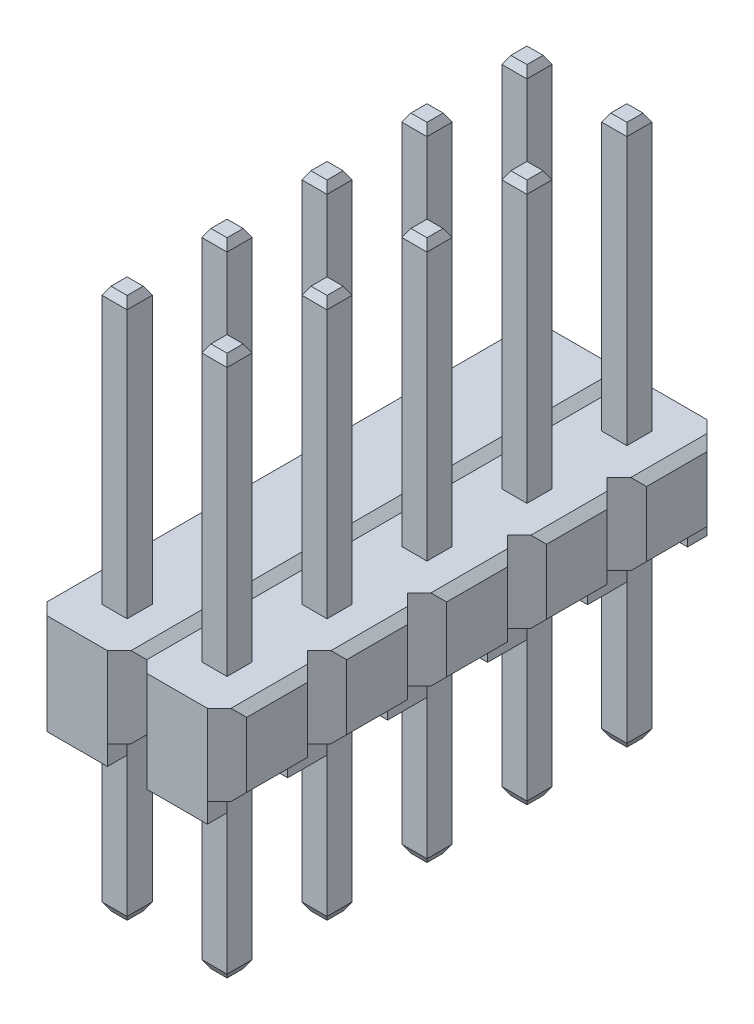
from build123d import *

# Parameters (mm, degrees)
SKETCH1_W                = 0.64
SKETCH1_H                = 0.64
BOSS_EXTRUDE1_DEPTH      = 2.05
CUT_EXTRUDE1_DEPTH       = 10
SKETCH3_W                = 1.54
SKETCH3_H                = 0.5
SKETCH3_H_2              = 1
BOSS_EXTRUDE2_DEPTH      = 0.5
SKETCH4_W                = 0.64
SKETCH4_H                = 0.64
BOSS_EXTRUDE3_DEPTH      = 7
BOSS_EXTRUDE3_DEPTH_BACK = 6.75
CHAMFER1_SIZE            = 0.2
CHAMFER1_SIZE2           = 0.115470054
CHAMFER1_PART_2_SIZE     = 0.2
CHAMFER1_PART_2_SIZE2    = 0.115470054
CHAMFER1_PART_3_SIZE     = 0.2
CHAMFER1_PART_3_SIZE2    = 0.115470054
CHAMFER1_PART_4_SIZE     = 0.2
CHAMFER1_PART_4_SIZE2    = 0.115470054
CHAMFER1_PART_5_SIZE     = 0.2
CHAMFER1_PART_5_SIZE2    = 0.115470054
CHAMFER1_PART_6_SIZE     = 0.2
CHAMFER1_PART_6_SIZE2    = 0.115470054
CHAMFER1_PART_7_SIZE     = 0.2
CHAMFER1_PART_7_SIZE2    = 0.115470054
CHAMFER1_PART_8_SIZE     = 0.2
CHAMFER1_PART_8_SIZE2    = 0.115470054
CHAMFER1_PART_9_SIZE     = 0.2
CHAMFER1_PART_9_SIZE2    = 0.115470054
CHAMFER1_PART_10_SIZE    = 0.2
CHAMFER1_PART_10_SIZE2   = 0.115470054
CHAMFER1_PART_11_SIZE    = 0.2
CHAMFER1_PART_11_SIZE2   = 0.115470054
CHAMFER1_PART_12_SIZE    = 0.2
CHAMFER1_PART_12_SIZE2   = 0.115470054
CHAMFER1_PART_13_SIZE    = 0.2
CHAMFER1_PART_13_SIZE2   = 0.115470054
CHAMFER1_PART_14_SIZE    = 0.2
CHAMFER1_PART_14_SIZE2   = 0.115470054
CHAMFER1_PART_15_SIZE    = 0.2
CHAMFER1_PART_15_SIZE2   = 0.115470054
CHAMFER1_PART_16_SIZE    = 0.2
CHAMFER1_PART_16_SIZE2   = 0.115470054
CHAMFER1_PART_17_SIZE    = 0.2
CHAMFER1_PART_17_SIZE2   = 0.115470054
CHAMFER1_PART_18_SIZE    = 0.2
CHAMFER1_PART_18_SIZE2   = 0.115470054
CHAMFER1_PART_19_SIZE    = 0.2
CHAMFER1_PART_19_SIZE2   = 0.115470054
CHAMFER1_PART_20_SIZE    = 0.2
CHAMFER1_PART_20_SIZE2   = 0.115470054
CHAMFER1_PART_21_SIZE    = 0.2
CHAMFER1_PART_21_SIZE2   = 0.115470054
CHAMFER1_PART_22_SIZE    = 0.2
CHAMFER1_PART_22_SIZE2   = 0.115470054
CHAMFER1_PART_23_SIZE    = 0.2
CHAMFER1_PART_23_SIZE2   = 0.115470054
CHAMFER1_PART_24_SIZE    = 0.2
CHAMFER1_PART_24_SIZE2   = 0.115470054
CHAMFER1_PART_25_SIZE    = 0.2
CHAMFER1_PART_25_SIZE2   = 0.115470054
CHAMFER1_PART_26_SIZE    = 0.2
CHAMFER1_PART_26_SIZE2   = 0.115470054
CHAMFER1_PART_27_SIZE    = 0.2
CHAMFER1_PART_27_SIZE2   = 0.115470054
CHAMFER1_PART_28_SIZE    = 0.2
CHAMFER1_PART_28_SIZE2   = 0.115470054
CHAMFER1_PART_29_SIZE    = 0.2
CHAMFER1_PART_29_SIZE2   = 0.115470054
CHAMFER1_PART_30_SIZE    = 0.2
CHAMFER1_PART_30_SIZE2   = 0.115470054
CHAMFER1_PART_31_SIZE    = 0.2
CHAMFER1_PART_31_SIZE2   = 0.115470054
CHAMFER1_PART_32_SIZE    = 0.2
CHAMFER1_PART_32_SIZE2   = 0.115470054
CHAMFER1_PART_33_SIZE    = 0.2
CHAMFER1_PART_33_SIZE2   = 0.115470054
CHAMFER1_PART_34_SIZE    = 0.2
CHAMFER1_PART_34_SIZE2   = 0.115470054
CHAMFER1_PART_35_SIZE    = 0.2
CHAMFER1_PART_35_SIZE2   = 0.115470054
CHAMFER1_PART_36_SIZE    = 0.2
CHAMFER1_PART_36_SIZE2   = 0.115470054
CHAMFER1_PART_37_SIZE    = 0.2
CHAMFER1_PART_37_SIZE2   = 0.115470054
CHAMFER1_PART_38_SIZE    = 0.2
CHAMFER1_PART_38_SIZE2   = 0.115470054
CHAMFER1_PART_39_SIZE    = 0.2
CHAMFER1_PART_39_SIZE2   = 0.115470054
CHAMFER1_PART_40_SIZE    = 0.2
CHAMFER1_PART_40_SIZE2   = 0.115470054
CHAMFER1_PART_41_SIZE    = 0.2
CHAMFER1_PART_41_SIZE2   = 0.115470054
CHAMFER1_PART_42_SIZE    = 0.2
CHAMFER1_PART_42_SIZE2   = 0.115470054
CHAMFER1_PART_43_SIZE    = 0.2
CHAMFER1_PART_43_SIZE2   = 0.115470054
CHAMFER1_PART_44_SIZE    = 0.2
CHAMFER1_PART_44_SIZE2   = 0.115470054
CHAMFER1_PART_45_SIZE    = 0.2
CHAMFER1_PART_45_SIZE2   = 0.115470054
CHAMFER1_PART_46_SIZE    = 0.2
CHAMFER1_PART_46_SIZE2   = 0.115470054
CHAMFER1_PART_47_SIZE    = 0.2
CHAMFER1_PART_47_SIZE2   = 0.115470054
CHAMFER1_PART_48_SIZE    = 0.2
CHAMFER1_PART_48_SIZE2   = 0.115470054
CHAMFER1_PART_49_SIZE    = 0.2
CHAMFER1_PART_49_SIZE2   = 0.115470054
CHAMFER1_PART_50_SIZE    = 0.2
CHAMFER1_PART_50_SIZE2   = 0.115470054
CHAMFER1_PART_51_SIZE    = 0.2
CHAMFER1_PART_51_SIZE2   = 0.115470054
CHAMFER1_PART_52_SIZE    = 0.2
CHAMFER1_PART_52_SIZE2   = 0.115470054
CHAMFER1_PART_53_SIZE    = 0.2
CHAMFER1_PART_53_SIZE2   = 0.115470054
CHAMFER1_PART_54_SIZE    = 0.2
CHAMFER1_PART_54_SIZE2   = 0.115470054
CHAMFER1_PART_55_SIZE    = 0.2
CHAMFER1_PART_55_SIZE2   = 0.115470054
CHAMFER1_PART_56_SIZE    = 0.2
CHAMFER1_PART_56_SIZE2   = 0.115470054
CHAMFER1_PART_57_SIZE    = 0.2
CHAMFER1_PART_57_SIZE2   = 0.115470054
CHAMFER1_PART_58_SIZE    = 0.2
CHAMFER1_PART_58_SIZE2   = 0.115470054
CHAMFER1_PART_59_SIZE    = 0.2
CHAMFER1_PART_59_SIZE2   = 0.115470054
CHAMFER1_PART_60_SIZE    = 0.2
CHAMFER1_PART_60_SIZE2   = 0.115470054
CHAMFER1_PART_61_SIZE    = 0.2
CHAMFER1_PART_61_SIZE2   = 0.115470054
CHAMFER1_PART_62_SIZE    = 0.2
CHAMFER1_PART_62_SIZE2   = 0.115470054
CHAMFER1_PART_63_SIZE    = 0.2
CHAMFER1_PART_63_SIZE2   = 0.115470054
CHAMFER1_PART_64_SIZE    = 0.2
CHAMFER1_PART_64_SIZE2   = 0.115470054
CHAMFER1_PART_65_SIZE    = 0.2
CHAMFER1_PART_65_SIZE2   = 0.115470054
CHAMFER1_PART_66_SIZE    = 0.2
CHAMFER1_PART_66_SIZE2   = 0.115470054
CHAMFER1_PART_67_SIZE    = 0.2
CHAMFER1_PART_67_SIZE2   = 0.115470054
CHAMFER1_PART_68_SIZE    = 0.2
CHAMFER1_PART_68_SIZE2   = 0.115470054
CHAMFER1_PART_69_SIZE    = 0.2
CHAMFER1_PART_69_SIZE2   = 0.115470054
CHAMFER1_PART_70_SIZE    = 0.2
CHAMFER1_PART_70_SIZE2   = 0.115470054
CHAMFER1_PART_71_SIZE    = 0.2
CHAMFER1_PART_71_SIZE2   = 0.115470054
CHAMFER1_PART_72_SIZE    = 0.2
CHAMFER1_PART_72_SIZE2   = 0.115470054
CHAMFER1_PART_73_SIZE    = 0.2
CHAMFER1_PART_73_SIZE2   = 0.115470054
CHAMFER1_PART_74_SIZE    = 0.2
CHAMFER1_PART_74_SIZE2   = 0.115470054
CHAMFER1_PART_75_SIZE    = 0.2
CHAMFER1_PART_75_SIZE2   = 0.115470054
CHAMFER1_PART_76_SIZE    = 0.2
CHAMFER1_PART_76_SIZE2   = 0.115470054
CHAMFER1_PART_77_SIZE    = 0.2
CHAMFER1_PART_77_SIZE2   = 0.115470054
CHAMFER1_PART_78_SIZE    = 0.2
CHAMFER1_PART_78_SIZE2   = 0.115470054
CHAMFER1_PART_79_SIZE    = 0.2
CHAMFER1_PART_79_SIZE2   = 0.115470054
CHAMFER1_PART_80_SIZE    = 0.2
CHAMFER1_PART_80_SIZE2   = 0.115470054
SKETCH5_R                = 0.125
CUT_EXTRUDE2_DEPTH       = 1
SCALE1_SCALE             = 0.5


with BuildPart() as part:
    # Sketch1 → Boss-Extrude1 (new body)
    with BuildSketch(Plane(origin=(0, 0, 0), x_dir=(1, 0, 0), z_dir=(0, 1, 0))):
        Polygon((2.04, 1.27), (2.54, 0.77), (2.54, -0.77), (2.04, -1.27), (2.54, -1.77), (2.54, -3.31), (2.04, -3.81), (2.54, -4.31), (2.54, -5.85), (2.04, -6.35), (0.5, -6.35), (0, -5.85), (-0.5, -6.35), (-2.04, -6.35), (-2.54, -5.85), (-2.54, -4.31), (-2.04, -3.81), (-2.54, -3.31), (-2.54, -1.77), (-2.04, -1.27), (-2.54, -0.77), (-2.54, 0.77), (-2.04, 1.27), (-2.54, 1.77), (-2.54, 3.31), (-2.04, 3.81), (-2.54, 4.31), (-2.54, 5.85), (-2.04, 6.35), (-0.5, 6.35), (0, 5.85), (0.5, 6.35), (2.04, 6.35), (2.54, 5.85), (2.54, 4.31), (2.04, 3.81), (2.54, 3.31), (2.54, 1.77), align=None)
        Polygon((0, 0.77), (0.5, 1.27), (0, 1.77), (-0.5, 1.27), align=None, mode=Mode.SUBTRACT)
        Polygon((0, 4.31), (-0.5, 3.81), (0, 3.31), (0.5, 3.81), align=None, mode=Mode.SUBTRACT)
        Polygon((0.5, -1.27), (0, -0.77), (-0.5, -1.27), (0, -1.77), align=None, mode=Mode.SUBTRACT)
        with Locations((-1.27, 0)):
            Rectangle(SKETCH1_W, SKETCH1_H, mode=Mode.SUBTRACT)
        with Locations((1.27, 0)):
            Rectangle(SKETCH1_W, SKETCH1_H, mode=Mode.SUBTRACT)
        with Locations((1.27, 5.08)):
            Rectangle(SKETCH1_W, SKETCH1_H, mode=Mode.SUBTRACT)
        with Locations((1.27, 2.54)):
            Rectangle(SKETCH1_W, SKETCH1_H, mode=Mode.SUBTRACT)
        with Locations((-1.27, 2.54)):
            Rectangle(SKETCH1_W, SKETCH1_H, mode=Mode.SUBTRACT)
        Polygon((0, -4.31), (0.5, -3.81), (0, -3.31), (-0.5, -3.81), align=None, mode=Mode.SUBTRACT)
        with Locations((-1.27, 5.08)):
            Rectangle(SKETCH1_W, SKETCH1_H, mode=Mode.SUBTRACT)
        with Locations((-1.27, -5.08)):
            Rectangle(SKETCH1_W, SKETCH1_H, mode=Mode.SUBTRACT)
        with Locations((1.27, -5.08)):
            Rectangle(SKETCH1_W, SKETCH1_H, mode=Mode.SUBTRACT)
        with Locations((1.27, -2.54)):
            Rectangle(SKETCH1_W, SKETCH1_H, mode=Mode.SUBTRACT)
        with Locations((-1.27, -2.54)):
            Rectangle(SKETCH1_W, SKETCH1_H, mode=Mode.SUBTRACT)
    extrude(amount=-BOSS_EXTRUDE1_DEPTH)

    # Sketch2 → Cut-Extrude1 (cut, symmetric)
    with BuildSketch(Plane.XY):
        Polygon((-2.54, -0.2), (-2.34, 0), (-2.54, 0), align=None)
        Polygon((-0.2, 0), (0.2, 0), (0, -0.2), align=None)
        Polygon((2.54, 0), (2.34, 0), (2.54, -0.2), align=None)
        Polygon((2.54, -1.85), (2.54, -2.05), (2.34, -2.05), align=None)
        Polygon((0, -1.85), (-0.2, -2.05), (0.2, -2.05), align=None)
        Polygon((-2.54, -2.05), (-2.54, -1.85), (-2.34, -2.05), align=None)
    extrude(amount=CUT_EXTRUDE1_DEPTH, both=True, mode=Mode.SUBTRACT)

    # Sketch3 → Boss-Extrude2 (add)
    with BuildSketch(Plane.XZ.offset(2.05)):
        with Locations((-1.27, 6.1)):
            Rectangle(SKETCH3_W, SKETCH3_H)
        with Locations((1.27, 6.1)):
            Rectangle(SKETCH3_W, SKETCH3_H)
        with Locations((-1.27, -1.27)):
            Rectangle(SKETCH3_W, SKETCH3_H_2)
        with Locations((1.27, -1.27)):
            Rectangle(SKETCH3_W, SKETCH3_H_2)
        with Locations((-1.27, -3.81)):
            Rectangle(SKETCH3_W, SKETCH3_H_2)
        with Locations((1.27, -3.81)):
            Rectangle(SKETCH3_W, SKETCH3_H_2)
        with Locations((-1.27, -6.1)):
            Rectangle(SKETCH3_W, SKETCH3_H)
        with Locations((1.27, -6.1)):
            Rectangle(SKETCH3_W, SKETCH3_H)
        with Locations((-1.27, 3.81)):
            Rectangle(SKETCH3_W, SKETCH3_H_2)
        with Locations((-1.27, 1.27)):
            Rectangle(SKETCH3_W, SKETCH3_H_2)
        with Locations((1.27, 3.81)):
            Rectangle(SKETCH3_W, SKETCH3_H_2)
        with Locations((1.27, 1.27)):
            Rectangle(SKETCH3_W, SKETCH3_H_2)
    extrude(amount=BOSS_EXTRUDE2_DEPTH)

    # Sketch4 → Boss-Extrude3 (add, two sides)
    with BuildSketch(Plane(origin=(0, 0, 0), x_dir=(1, 0, 0), z_dir=(0, 1, 0))) as boss_extrude3_sk:
        with Locations((-1.27, 5.08)):
            Rectangle(SKETCH4_W, SKETCH4_H)
        with Locations((1.27, 5.08)):
            Rectangle(SKETCH4_W, SKETCH4_H)
        with Locations((-1.27, 2.54)):
            Rectangle(SKETCH4_W, SKETCH4_H)
        with Locations((1.27, 2.54)):
            Rectangle(SKETCH4_W, SKETCH4_H)
        with Locations((-1.27, 0)):
            Rectangle(SKETCH4_W, SKETCH4_H)
        with Locations((1.27, 0)):
            Rectangle(SKETCH4_W, SKETCH4_H)
        with Locations((-1.27, -2.54)):
            Rectangle(SKETCH4_W, SKETCH4_H)
        with Locations((1.27, -2.54)):
            Rectangle(SKETCH4_W, SKETCH4_H)
        with Locations((-1.27, -5.08)):
            Rectangle(SKETCH4_W, SKETCH4_H)
        with Locations((1.27, -5.08)):
            Rectangle(SKETCH4_W, SKETCH4_H)
    extrude(amount=BOSS_EXTRUDE3_DEPTH)
    extrude(boss_extrude3_sk.sketch, amount=-BOSS_EXTRUDE3_DEPTH_BACK)

    # Chamfer1
    chamfer1_edges = [part.edges().sort_by_distance(p)[0] for p in [
        (-1.59, -6.75, -5.08),
    ]]
    chamfer1_side = [part.faces().sort_by_distance(p)[0] for p in [
        (-1.59, -4.4, -5.08),
    ]]
    chamfer(chamfer1_edges, length=CHAMFER1_SIZE, length2=CHAMFER1_SIZE2, reference=chamfer1_side[0])

    # Chamfer1 part 2
    chamfer1_part_2_edges = [part.edges().sort_by_distance(p)[0] for p in [
        (-1.27, -6.75, -5.4),
    ]]
    chamfer1_part_2_side = [part.faces().sort_by_distance(p)[0] for p in [
        (-1.27, -4.4, -5.4),
    ]]
    chamfer(chamfer1_part_2_edges, length=CHAMFER1_PART_2_SIZE, length2=CHAMFER1_PART_2_SIZE2, reference=chamfer1_part_2_side[0])

    # Chamfer1 part 3
    chamfer1_part_3_edges = [part.edges().sort_by_distance(p)[0] for p in [
        (-0.95, -6.75, -5.08),
    ]]
    chamfer1_part_3_side = [part.faces().sort_by_distance(p)[0] for p in [
        (-0.95, -4.4, -5.08),
    ]]
    chamfer(chamfer1_part_3_edges, length=CHAMFER1_PART_3_SIZE, length2=CHAMFER1_PART_3_SIZE2, reference=chamfer1_part_3_side[0])

    # Chamfer1 part 4
    chamfer1_part_4_edges = [part.edges().sort_by_distance(p)[0] for p in [
        (-1.27, -6.75, -4.76),
    ]]
    chamfer1_part_4_side = [part.faces().sort_by_distance(p)[0] for p in [
        (-1.27, -4.4, -4.76),
    ]]
    chamfer(chamfer1_part_4_edges, length=CHAMFER1_PART_4_SIZE, length2=CHAMFER1_PART_4_SIZE2, reference=chamfer1_part_4_side[0])

    # Chamfer1 part 5
    chamfer1_part_5_edges = [part.edges().sort_by_distance(p)[0] for p in [
        (-1.59, 7, -5.08),
    ]]
    chamfer1_part_5_side = [part.faces().sort_by_distance(p)[0] for p in [
        (-1.59, 3.5, -5.08),
    ]]
    chamfer(chamfer1_part_5_edges, length=CHAMFER1_PART_5_SIZE, length2=CHAMFER1_PART_5_SIZE2, reference=chamfer1_part_5_side[0])

    # Chamfer1 part 6
    chamfer1_part_6_edges = [part.edges().sort_by_distance(p)[0] for p in [
        (-1.27, 7, -4.76),
    ]]
    chamfer1_part_6_side = [part.faces().sort_by_distance(p)[0] for p in [
        (-1.27, 3.5, -4.76),
    ]]
    chamfer(chamfer1_part_6_edges, length=CHAMFER1_PART_6_SIZE, length2=CHAMFER1_PART_6_SIZE2, reference=chamfer1_part_6_side[0])

    # Chamfer1 part 7
    chamfer1_part_7_edges = [part.edges().sort_by_distance(p)[0] for p in [
        (-0.95, 7, -5.08),
    ]]
    chamfer1_part_7_side = [part.faces().sort_by_distance(p)[0] for p in [
        (-0.95, 3.5, -5.08),
    ]]
    chamfer(chamfer1_part_7_edges, length=CHAMFER1_PART_7_SIZE, length2=CHAMFER1_PART_7_SIZE2, reference=chamfer1_part_7_side[0])

    # Chamfer1 part 8
    chamfer1_part_8_edges = [part.edges().sort_by_distance(p)[0] for p in [
        (-1.27, 7, -5.4),
    ]]
    chamfer1_part_8_side = [part.faces().sort_by_distance(p)[0] for p in [
        (-1.27, 3.5, -5.4),
    ]]
    chamfer(chamfer1_part_8_edges, length=CHAMFER1_PART_8_SIZE, length2=CHAMFER1_PART_8_SIZE2, reference=chamfer1_part_8_side[0])

    # Chamfer1 part 9
    chamfer1_part_9_edges = [part.edges().sort_by_distance(p)[0] for p in [
        (0.95, -6.75, -5.08),
    ]]
    chamfer1_part_9_side = [part.faces().sort_by_distance(p)[0] for p in [
        (0.95, -4.4, -5.08),
    ]]
    chamfer(chamfer1_part_9_edges, length=CHAMFER1_PART_9_SIZE, length2=CHAMFER1_PART_9_SIZE2, reference=chamfer1_part_9_side[0])

    # Chamfer1 part 10
    chamfer1_part_10_edges = [part.edges().sort_by_distance(p)[0] for p in [
        (1.27, -6.75, -5.4),
    ]]
    chamfer1_part_10_side = [part.faces().sort_by_distance(p)[0] for p in [
        (1.27, -4.4, -5.4),
    ]]
    chamfer(chamfer1_part_10_edges, length=CHAMFER1_PART_10_SIZE, length2=CHAMFER1_PART_10_SIZE2, reference=chamfer1_part_10_side[0])

    # Chamfer1 part 11
    chamfer1_part_11_edges = [part.edges().sort_by_distance(p)[0] for p in [
        (1.59, -6.75, -5.08),
    ]]
    chamfer1_part_11_side = [part.faces().sort_by_distance(p)[0] for p in [
        (1.59, -4.4, -5.08),
    ]]
    chamfer(chamfer1_part_11_edges, length=CHAMFER1_PART_11_SIZE, length2=CHAMFER1_PART_11_SIZE2, reference=chamfer1_part_11_side[0])

    # Chamfer1 part 12
    chamfer1_part_12_edges = [part.edges().sort_by_distance(p)[0] for p in [
        (1.27, -6.75, -4.76),
    ]]
    chamfer1_part_12_side = [part.faces().sort_by_distance(p)[0] for p in [
        (1.27, -4.4, -4.76),
    ]]
    chamfer(chamfer1_part_12_edges, length=CHAMFER1_PART_12_SIZE, length2=CHAMFER1_PART_12_SIZE2, reference=chamfer1_part_12_side[0])

    # Chamfer1 part 13
    chamfer1_part_13_edges = [part.edges().sort_by_distance(p)[0] for p in [
        (0.95, 7, -5.08),
    ]]
    chamfer1_part_13_side = [part.faces().sort_by_distance(p)[0] for p in [
        (0.95, 3.5, -5.08),
    ]]
    chamfer(chamfer1_part_13_edges, length=CHAMFER1_PART_13_SIZE, length2=CHAMFER1_PART_13_SIZE2, reference=chamfer1_part_13_side[0])

    # Chamfer1 part 14
    chamfer1_part_14_edges = [part.edges().sort_by_distance(p)[0] for p in [
        (1.27, 7, -4.76),
    ]]
    chamfer1_part_14_side = [part.faces().sort_by_distance(p)[0] for p in [
        (1.27, 3.5, -4.76),
    ]]
    chamfer(chamfer1_part_14_edges, length=CHAMFER1_PART_14_SIZE, length2=CHAMFER1_PART_14_SIZE2, reference=chamfer1_part_14_side[0])

    # Chamfer1 part 15
    chamfer1_part_15_edges = [part.edges().sort_by_distance(p)[0] for p in [
        (1.59, 7, -5.08),
    ]]
    chamfer1_part_15_side = [part.faces().sort_by_distance(p)[0] for p in [
        (1.59, 3.5, -5.08),
    ]]
    chamfer(chamfer1_part_15_edges, length=CHAMFER1_PART_15_SIZE, length2=CHAMFER1_PART_15_SIZE2, reference=chamfer1_part_15_side[0])

    # Chamfer1 part 16
    chamfer1_part_16_edges = [part.edges().sort_by_distance(p)[0] for p in [
        (1.27, 7, -5.4),
    ]]
    chamfer1_part_16_side = [part.faces().sort_by_distance(p)[0] for p in [
        (1.27, 3.5, -5.4),
    ]]
    chamfer(chamfer1_part_16_edges, length=CHAMFER1_PART_16_SIZE, length2=CHAMFER1_PART_16_SIZE2, reference=chamfer1_part_16_side[0])

    # Chamfer1 part 17
    chamfer1_part_17_edges = [part.edges().sort_by_distance(p)[0] for p in [
        (-1.59, -6.75, -2.54),
    ]]
    chamfer1_part_17_side = [part.faces().sort_by_distance(p)[0] for p in [
        (-1.59, -4.4, -2.54),
    ]]
    chamfer(chamfer1_part_17_edges, length=CHAMFER1_PART_17_SIZE, length2=CHAMFER1_PART_17_SIZE2, reference=chamfer1_part_17_side[0])

    # Chamfer1 part 18
    chamfer1_part_18_edges = [part.edges().sort_by_distance(p)[0] for p in [
        (-1.27, -6.75, -2.86),
    ]]
    chamfer1_part_18_side = [part.faces().sort_by_distance(p)[0] for p in [
        (-1.27, -4.4, -2.86),
    ]]
    chamfer(chamfer1_part_18_edges, length=CHAMFER1_PART_18_SIZE, length2=CHAMFER1_PART_18_SIZE2, reference=chamfer1_part_18_side[0])

    # Chamfer1 part 19
    chamfer1_part_19_edges = [part.edges().sort_by_distance(p)[0] for p in [
        (-0.95, -6.75, -2.54),
    ]]
    chamfer1_part_19_side = [part.faces().sort_by_distance(p)[0] for p in [
        (-0.95, -4.4, -2.54),
    ]]
    chamfer(chamfer1_part_19_edges, length=CHAMFER1_PART_19_SIZE, length2=CHAMFER1_PART_19_SIZE2, reference=chamfer1_part_19_side[0])

    # Chamfer1 part 20
    chamfer1_part_20_edges = [part.edges().sort_by_distance(p)[0] for p in [
        (-1.27, -6.75, -2.22),
    ]]
    chamfer1_part_20_side = [part.faces().sort_by_distance(p)[0] for p in [
        (-1.27, -4.4, -2.22),
    ]]
    chamfer(chamfer1_part_20_edges, length=CHAMFER1_PART_20_SIZE, length2=CHAMFER1_PART_20_SIZE2, reference=chamfer1_part_20_side[0])

    # Chamfer1 part 21
    chamfer1_part_21_edges = [part.edges().sort_by_distance(p)[0] for p in [
        (-1.59, 7, -2.54),
    ]]
    chamfer1_part_21_side = [part.faces().sort_by_distance(p)[0] for p in [
        (-1.59, 3.5, -2.54),
    ]]
    chamfer(chamfer1_part_21_edges, length=CHAMFER1_PART_21_SIZE, length2=CHAMFER1_PART_21_SIZE2, reference=chamfer1_part_21_side[0])

    # Chamfer1 part 22
    chamfer1_part_22_edges = [part.edges().sort_by_distance(p)[0] for p in [
        (-1.27, 7, -2.22),
    ]]
    chamfer1_part_22_side = [part.faces().sort_by_distance(p)[0] for p in [
        (-1.27, 3.5, -2.22),
    ]]
    chamfer(chamfer1_part_22_edges, length=CHAMFER1_PART_22_SIZE, length2=CHAMFER1_PART_22_SIZE2, reference=chamfer1_part_22_side[0])

    # Chamfer1 part 23
    chamfer1_part_23_edges = [part.edges().sort_by_distance(p)[0] for p in [
        (-0.95, 7, -2.54),
    ]]
    chamfer1_part_23_side = [part.faces().sort_by_distance(p)[0] for p in [
        (-0.95, 3.5, -2.54),
    ]]
    chamfer(chamfer1_part_23_edges, length=CHAMFER1_PART_23_SIZE, length2=CHAMFER1_PART_23_SIZE2, reference=chamfer1_part_23_side[0])

    # Chamfer1 part 24
    chamfer1_part_24_edges = [part.edges().sort_by_distance(p)[0] for p in [
        (-1.27, 7, -2.86),
    ]]
    chamfer1_part_24_side = [part.faces().sort_by_distance(p)[0] for p in [
        (-1.27, 3.5, -2.86),
    ]]
    chamfer(chamfer1_part_24_edges, length=CHAMFER1_PART_24_SIZE, length2=CHAMFER1_PART_24_SIZE2, reference=chamfer1_part_24_side[0])

    # Chamfer1 part 25
    chamfer1_part_25_edges = [part.edges().sort_by_distance(p)[0] for p in [
        (0.95, -6.75, -2.54),
    ]]
    chamfer1_part_25_side = [part.faces().sort_by_distance(p)[0] for p in [
        (0.95, -4.4, -2.54),
    ]]
    chamfer(chamfer1_part_25_edges, length=CHAMFER1_PART_25_SIZE, length2=CHAMFER1_PART_25_SIZE2, reference=chamfer1_part_25_side[0])

    # Chamfer1 part 26
    chamfer1_part_26_edges = [part.edges().sort_by_distance(p)[0] for p in [
        (1.27, -6.75, -2.86),
    ]]
    chamfer1_part_26_side = [part.faces().sort_by_distance(p)[0] for p in [
        (1.27, -4.4, -2.86),
    ]]
    chamfer(chamfer1_part_26_edges, length=CHAMFER1_PART_26_SIZE, length2=CHAMFER1_PART_26_SIZE2, reference=chamfer1_part_26_side[0])

    # Chamfer1 part 27
    chamfer1_part_27_edges = [part.edges().sort_by_distance(p)[0] for p in [
        (1.59, -6.75, -2.54),
    ]]
    chamfer1_part_27_side = [part.faces().sort_by_distance(p)[0] for p in [
        (1.59, -4.4, -2.54),
    ]]
    chamfer(chamfer1_part_27_edges, length=CHAMFER1_PART_27_SIZE, length2=CHAMFER1_PART_27_SIZE2, reference=chamfer1_part_27_side[0])

    # Chamfer1 part 28
    chamfer1_part_28_edges = [part.edges().sort_by_distance(p)[0] for p in [
        (1.27, -6.75, -2.22),
    ]]
    chamfer1_part_28_side = [part.faces().sort_by_distance(p)[0] for p in [
        (1.27, -4.4, -2.22),
    ]]
    chamfer(chamfer1_part_28_edges, length=CHAMFER1_PART_28_SIZE, length2=CHAMFER1_PART_28_SIZE2, reference=chamfer1_part_28_side[0])

    # Chamfer1 part 29
    chamfer1_part_29_edges = [part.edges().sort_by_distance(p)[0] for p in [
        (0.95, 7, -2.54),
    ]]
    chamfer1_part_29_side = [part.faces().sort_by_distance(p)[0] for p in [
        (0.95, 3.5, -2.54),
    ]]
    chamfer(chamfer1_part_29_edges, length=CHAMFER1_PART_29_SIZE, length2=CHAMFER1_PART_29_SIZE2, reference=chamfer1_part_29_side[0])

    # Chamfer1 part 30
    chamfer1_part_30_edges = [part.edges().sort_by_distance(p)[0] for p in [
        (1.27, 7, -2.22),
    ]]
    chamfer1_part_30_side = [part.faces().sort_by_distance(p)[0] for p in [
        (1.27, 3.5, -2.22),
    ]]
    chamfer(chamfer1_part_30_edges, length=CHAMFER1_PART_30_SIZE, length2=CHAMFER1_PART_30_SIZE2, reference=chamfer1_part_30_side[0])

    # Chamfer1 part 31
    chamfer1_part_31_edges = [part.edges().sort_by_distance(p)[0] for p in [
        (1.59, 7, -2.54),
    ]]
    chamfer1_part_31_side = [part.faces().sort_by_distance(p)[0] for p in [
        (1.59, 3.5, -2.54),
    ]]
    chamfer(chamfer1_part_31_edges, length=CHAMFER1_PART_31_SIZE, length2=CHAMFER1_PART_31_SIZE2, reference=chamfer1_part_31_side[0])

    # Chamfer1 part 32
    chamfer1_part_32_edges = [part.edges().sort_by_distance(p)[0] for p in [
        (1.27, 7, -2.86),
    ]]
    chamfer1_part_32_side = [part.faces().sort_by_distance(p)[0] for p in [
        (1.27, 3.5, -2.86),
    ]]
    chamfer(chamfer1_part_32_edges, length=CHAMFER1_PART_32_SIZE, length2=CHAMFER1_PART_32_SIZE2, reference=chamfer1_part_32_side[0])

    # Chamfer1 part 33
    chamfer1_part_33_edges = [part.edges().sort_by_distance(p)[0] for p in [
        (-1.59, -6.75, 0),
    ]]
    chamfer1_part_33_side = [part.faces().sort_by_distance(p)[0] for p in [
        (-1.59, -4.4, 0),
    ]]
    chamfer(chamfer1_part_33_edges, length=CHAMFER1_PART_33_SIZE, length2=CHAMFER1_PART_33_SIZE2, reference=chamfer1_part_33_side[0])

    # Chamfer1 part 34
    chamfer1_part_34_edges = [part.edges().sort_by_distance(p)[0] for p in [
        (-1.27, -6.75, -0.32),
    ]]
    chamfer1_part_34_side = [part.faces().sort_by_distance(p)[0] for p in [
        (-1.27, -4.4, -0.32),
    ]]
    chamfer(chamfer1_part_34_edges, length=CHAMFER1_PART_34_SIZE, length2=CHAMFER1_PART_34_SIZE2, reference=chamfer1_part_34_side[0])

    # Chamfer1 part 35
    chamfer1_part_35_edges = [part.edges().sort_by_distance(p)[0] for p in [
        (-0.95, -6.75, 0),
    ]]
    chamfer1_part_35_side = [part.faces().sort_by_distance(p)[0] for p in [
        (-0.95, -4.4, 0),
    ]]
    chamfer(chamfer1_part_35_edges, length=CHAMFER1_PART_35_SIZE, length2=CHAMFER1_PART_35_SIZE2, reference=chamfer1_part_35_side[0])

    # Chamfer1 part 36
    chamfer1_part_36_edges = [part.edges().sort_by_distance(p)[0] for p in [
        (-1.27, -6.75, 0.32),
    ]]
    chamfer1_part_36_side = [part.faces().sort_by_distance(p)[0] for p in [
        (-1.27, -4.4, 0.32),
    ]]
    chamfer(chamfer1_part_36_edges, length=CHAMFER1_PART_36_SIZE, length2=CHAMFER1_PART_36_SIZE2, reference=chamfer1_part_36_side[0])

    # Chamfer1 part 37
    chamfer1_part_37_edges = [part.edges().sort_by_distance(p)[0] for p in [
        (-1.59, 7, 0),
    ]]
    chamfer1_part_37_side = [part.faces().sort_by_distance(p)[0] for p in [
        (-1.59, 3.5, 0),
    ]]
    chamfer(chamfer1_part_37_edges, length=CHAMFER1_PART_37_SIZE, length2=CHAMFER1_PART_37_SIZE2, reference=chamfer1_part_37_side[0])

    # Chamfer1 part 38
    chamfer1_part_38_edges = [part.edges().sort_by_distance(p)[0] for p in [
        (-1.27, 7, 0.32),
    ]]
    chamfer1_part_38_side = [part.faces().sort_by_distance(p)[0] for p in [
        (-1.27, 3.5, 0.32),
    ]]
    chamfer(chamfer1_part_38_edges, length=CHAMFER1_PART_38_SIZE, length2=CHAMFER1_PART_38_SIZE2, reference=chamfer1_part_38_side[0])

    # Chamfer1 part 39
    chamfer1_part_39_edges = [part.edges().sort_by_distance(p)[0] for p in [
        (-0.95, 7, 0),
    ]]
    chamfer1_part_39_side = [part.faces().sort_by_distance(p)[0] for p in [
        (-0.95, 3.5, 0),
    ]]
    chamfer(chamfer1_part_39_edges, length=CHAMFER1_PART_39_SIZE, length2=CHAMFER1_PART_39_SIZE2, reference=chamfer1_part_39_side[0])

    # Chamfer1 part 40
    chamfer1_part_40_edges = [part.edges().sort_by_distance(p)[0] for p in [
        (-1.27, 7, -0.32),
    ]]
    chamfer1_part_40_side = [part.faces().sort_by_distance(p)[0] for p in [
        (-1.27, 3.5, -0.32),
    ]]
    chamfer(chamfer1_part_40_edges, length=CHAMFER1_PART_40_SIZE, length2=CHAMFER1_PART_40_SIZE2, reference=chamfer1_part_40_side[0])

    # Chamfer1 part 41
    chamfer1_part_41_edges = [part.edges().sort_by_distance(p)[0] for p in [
        (0.95, -6.75, 0),
    ]]
    chamfer1_part_41_side = [part.faces().sort_by_distance(p)[0] for p in [
        (0.95, -4.4, 0),
    ]]
    chamfer(chamfer1_part_41_edges, length=CHAMFER1_PART_41_SIZE, length2=CHAMFER1_PART_41_SIZE2, reference=chamfer1_part_41_side[0])

    # Chamfer1 part 42
    chamfer1_part_42_edges = [part.edges().sort_by_distance(p)[0] for p in [
        (1.27, -6.75, -0.32),
    ]]
    chamfer1_part_42_side = [part.faces().sort_by_distance(p)[0] for p in [
        (1.27, -4.4, -0.32),
    ]]
    chamfer(chamfer1_part_42_edges, length=CHAMFER1_PART_42_SIZE, length2=CHAMFER1_PART_42_SIZE2, reference=chamfer1_part_42_side[0])

    # Chamfer1 part 43
    chamfer1_part_43_edges = [part.edges().sort_by_distance(p)[0] for p in [
        (1.59, -6.75, 0),
    ]]
    chamfer1_part_43_side = [part.faces().sort_by_distance(p)[0] for p in [
        (1.59, -4.4, 0),
    ]]
    chamfer(chamfer1_part_43_edges, length=CHAMFER1_PART_43_SIZE, length2=CHAMFER1_PART_43_SIZE2, reference=chamfer1_part_43_side[0])

    # Chamfer1 part 44
    chamfer1_part_44_edges = [part.edges().sort_by_distance(p)[0] for p in [
        (1.27, -6.75, 0.32),
    ]]
    chamfer1_part_44_side = [part.faces().sort_by_distance(p)[0] for p in [
        (1.27, -4.4, 0.32),
    ]]
    chamfer(chamfer1_part_44_edges, length=CHAMFER1_PART_44_SIZE, length2=CHAMFER1_PART_44_SIZE2, reference=chamfer1_part_44_side[0])

    # Chamfer1 part 45
    chamfer1_part_45_edges = [part.edges().sort_by_distance(p)[0] for p in [
        (0.95, 7, 0),
    ]]
    chamfer1_part_45_side = [part.faces().sort_by_distance(p)[0] for p in [
        (0.95, 3.5, 0),
    ]]
    chamfer(chamfer1_part_45_edges, length=CHAMFER1_PART_45_SIZE, length2=CHAMFER1_PART_45_SIZE2, reference=chamfer1_part_45_side[0])

    # Chamfer1 part 46
    chamfer1_part_46_edges = [part.edges().sort_by_distance(p)[0] for p in [
        (1.27, 7, 0.32),
    ]]
    chamfer1_part_46_side = [part.faces().sort_by_distance(p)[0] for p in [
        (1.27, 3.5, 0.32),
    ]]
    chamfer(chamfer1_part_46_edges, length=CHAMFER1_PART_46_SIZE, length2=CHAMFER1_PART_46_SIZE2, reference=chamfer1_part_46_side[0])

    # Chamfer1 part 47
    chamfer1_part_47_edges = [part.edges().sort_by_distance(p)[0] for p in [
        (1.59, 7, 0),
    ]]
    chamfer1_part_47_side = [part.faces().sort_by_distance(p)[0] for p in [
        (1.59, 3.5, 0),
    ]]
    chamfer(chamfer1_part_47_edges, length=CHAMFER1_PART_47_SIZE, length2=CHAMFER1_PART_47_SIZE2, reference=chamfer1_part_47_side[0])

    # Chamfer1 part 48
    chamfer1_part_48_edges = [part.edges().sort_by_distance(p)[0] for p in [
        (1.27, 7, -0.32),
    ]]
    chamfer1_part_48_side = [part.faces().sort_by_distance(p)[0] for p in [
        (1.27, 3.5, -0.32),
    ]]
    chamfer(chamfer1_part_48_edges, length=CHAMFER1_PART_48_SIZE, length2=CHAMFER1_PART_48_SIZE2, reference=chamfer1_part_48_side[0])

    # Chamfer1 part 49
    chamfer1_part_49_edges = [part.edges().sort_by_distance(p)[0] for p in [
        (-1.59, -6.75, 2.54),
    ]]
    chamfer1_part_49_side = [part.faces().sort_by_distance(p)[0] for p in [
        (-1.59, -4.4, 2.54),
    ]]
    chamfer(chamfer1_part_49_edges, length=CHAMFER1_PART_49_SIZE, length2=CHAMFER1_PART_49_SIZE2, reference=chamfer1_part_49_side[0])

    # Chamfer1 part 50
    chamfer1_part_50_edges = [part.edges().sort_by_distance(p)[0] for p in [
        (-1.27, -6.75, 2.22),
    ]]
    chamfer1_part_50_side = [part.faces().sort_by_distance(p)[0] for p in [
        (-1.27, -4.4, 2.22),
    ]]
    chamfer(chamfer1_part_50_edges, length=CHAMFER1_PART_50_SIZE, length2=CHAMFER1_PART_50_SIZE2, reference=chamfer1_part_50_side[0])

    # Chamfer1 part 51
    chamfer1_part_51_edges = [part.edges().sort_by_distance(p)[0] for p in [
        (-0.95, -6.75, 2.54),
    ]]
    chamfer1_part_51_side = [part.faces().sort_by_distance(p)[0] for p in [
        (-0.95, -4.4, 2.54),
    ]]
    chamfer(chamfer1_part_51_edges, length=CHAMFER1_PART_51_SIZE, length2=CHAMFER1_PART_51_SIZE2, reference=chamfer1_part_51_side[0])

    # Chamfer1 part 52
    chamfer1_part_52_edges = [part.edges().sort_by_distance(p)[0] for p in [
        (-1.27, -6.75, 2.86),
    ]]
    chamfer1_part_52_side = [part.faces().sort_by_distance(p)[0] for p in [
        (-1.27, -4.4, 2.86),
    ]]
    chamfer(chamfer1_part_52_edges, length=CHAMFER1_PART_52_SIZE, length2=CHAMFER1_PART_52_SIZE2, reference=chamfer1_part_52_side[0])

    # Chamfer1 part 53
    chamfer1_part_53_edges = [part.edges().sort_by_distance(p)[0] for p in [
        (-1.59, 7, 2.54),
    ]]
    chamfer1_part_53_side = [part.faces().sort_by_distance(p)[0] for p in [
        (-1.59, 3.5, 2.54),
    ]]
    chamfer(chamfer1_part_53_edges, length=CHAMFER1_PART_53_SIZE, length2=CHAMFER1_PART_53_SIZE2, reference=chamfer1_part_53_side[0])

    # Chamfer1 part 54
    chamfer1_part_54_edges = [part.edges().sort_by_distance(p)[0] for p in [
        (-1.27, 7, 2.86),
    ]]
    chamfer1_part_54_side = [part.faces().sort_by_distance(p)[0] for p in [
        (-1.27, 3.5, 2.86),
    ]]
    chamfer(chamfer1_part_54_edges, length=CHAMFER1_PART_54_SIZE, length2=CHAMFER1_PART_54_SIZE2, reference=chamfer1_part_54_side[0])

    # Chamfer1 part 55
    chamfer1_part_55_edges = [part.edges().sort_by_distance(p)[0] for p in [
        (-0.95, 7, 2.54),
    ]]
    chamfer1_part_55_side = [part.faces().sort_by_distance(p)[0] for p in [
        (-0.95, 3.5, 2.54),
    ]]
    chamfer(chamfer1_part_55_edges, length=CHAMFER1_PART_55_SIZE, length2=CHAMFER1_PART_55_SIZE2, reference=chamfer1_part_55_side[0])

    # Chamfer1 part 56
    chamfer1_part_56_edges = [part.edges().sort_by_distance(p)[0] for p in [
        (-1.27, 7, 2.22),
    ]]
    chamfer1_part_56_side = [part.faces().sort_by_distance(p)[0] for p in [
        (-1.27, 3.5, 2.22),
    ]]
    chamfer(chamfer1_part_56_edges, length=CHAMFER1_PART_56_SIZE, length2=CHAMFER1_PART_56_SIZE2, reference=chamfer1_part_56_side[0])

    # Chamfer1 part 57
    chamfer1_part_57_edges = [part.edges().sort_by_distance(p)[0] for p in [
        (0.95, -6.75, 2.54),
    ]]
    chamfer1_part_57_side = [part.faces().sort_by_distance(p)[0] for p in [
        (0.95, -4.4, 2.54),
    ]]
    chamfer(chamfer1_part_57_edges, length=CHAMFER1_PART_57_SIZE, length2=CHAMFER1_PART_57_SIZE2, reference=chamfer1_part_57_side[0])

    # Chamfer1 part 58
    chamfer1_part_58_edges = [part.edges().sort_by_distance(p)[0] for p in [
        (1.27, -6.75, 2.22),
    ]]
    chamfer1_part_58_side = [part.faces().sort_by_distance(p)[0] for p in [
        (1.27, -4.4, 2.22),
    ]]
    chamfer(chamfer1_part_58_edges, length=CHAMFER1_PART_58_SIZE, length2=CHAMFER1_PART_58_SIZE2, reference=chamfer1_part_58_side[0])

    # Chamfer1 part 59
    chamfer1_part_59_edges = [part.edges().sort_by_distance(p)[0] for p in [
        (1.59, -6.75, 2.54),
    ]]
    chamfer1_part_59_side = [part.faces().sort_by_distance(p)[0] for p in [
        (1.59, -4.4, 2.54),
    ]]
    chamfer(chamfer1_part_59_edges, length=CHAMFER1_PART_59_SIZE, length2=CHAMFER1_PART_59_SIZE2, reference=chamfer1_part_59_side[0])

    # Chamfer1 part 60
    chamfer1_part_60_edges = [part.edges().sort_by_distance(p)[0] for p in [
        (1.27, -6.75, 2.86),
    ]]
    chamfer1_part_60_side = [part.faces().sort_by_distance(p)[0] for p in [
        (1.27, -4.4, 2.86),
    ]]
    chamfer(chamfer1_part_60_edges, length=CHAMFER1_PART_60_SIZE, length2=CHAMFER1_PART_60_SIZE2, reference=chamfer1_part_60_side[0])

    # Chamfer1 part 61
    chamfer1_part_61_edges = [part.edges().sort_by_distance(p)[0] for p in [
        (0.95, 7, 2.54),
    ]]
    chamfer1_part_61_side = [part.faces().sort_by_distance(p)[0] for p in [
        (0.95, 3.5, 2.54),
    ]]
    chamfer(chamfer1_part_61_edges, length=CHAMFER1_PART_61_SIZE, length2=CHAMFER1_PART_61_SIZE2, reference=chamfer1_part_61_side[0])

    # Chamfer1 part 62
    chamfer1_part_62_edges = [part.edges().sort_by_distance(p)[0] for p in [
        (1.27, 7, 2.86),
    ]]
    chamfer1_part_62_side = [part.faces().sort_by_distance(p)[0] for p in [
        (1.27, 3.5, 2.86),
    ]]
    chamfer(chamfer1_part_62_edges, length=CHAMFER1_PART_62_SIZE, length2=CHAMFER1_PART_62_SIZE2, reference=chamfer1_part_62_side[0])

    # Chamfer1 part 63
    chamfer1_part_63_edges = [part.edges().sort_by_distance(p)[0] for p in [
        (1.59, 7, 2.54),
    ]]
    chamfer1_part_63_side = [part.faces().sort_by_distance(p)[0] for p in [
        (1.59, 3.5, 2.54),
    ]]
    chamfer(chamfer1_part_63_edges, length=CHAMFER1_PART_63_SIZE, length2=CHAMFER1_PART_63_SIZE2, reference=chamfer1_part_63_side[0])

    # Chamfer1 part 64
    chamfer1_part_64_edges = [part.edges().sort_by_distance(p)[0] for p in [
        (1.27, 7, 2.22),
    ]]
    chamfer1_part_64_side = [part.faces().sort_by_distance(p)[0] for p in [
        (1.27, 3.5, 2.22),
    ]]
    chamfer(chamfer1_part_64_edges, length=CHAMFER1_PART_64_SIZE, length2=CHAMFER1_PART_64_SIZE2, reference=chamfer1_part_64_side[0])

    # Chamfer1 part 65
    chamfer1_part_65_edges = [part.edges().sort_by_distance(p)[0] for p in [
        (-1.59, -6.75, 5.08),
    ]]
    chamfer1_part_65_side = [part.faces().sort_by_distance(p)[0] for p in [
        (-1.59, -4.4, 5.08),
    ]]
    chamfer(chamfer1_part_65_edges, length=CHAMFER1_PART_65_SIZE, length2=CHAMFER1_PART_65_SIZE2, reference=chamfer1_part_65_side[0])

    # Chamfer1 part 66
    chamfer1_part_66_edges = [part.edges().sort_by_distance(p)[0] for p in [
        (-1.27, -6.75, 4.76),
    ]]
    chamfer1_part_66_side = [part.faces().sort_by_distance(p)[0] for p in [
        (-1.27, -4.4, 4.76),
    ]]
    chamfer(chamfer1_part_66_edges, length=CHAMFER1_PART_66_SIZE, length2=CHAMFER1_PART_66_SIZE2, reference=chamfer1_part_66_side[0])

    # Chamfer1 part 67
    chamfer1_part_67_edges = [part.edges().sort_by_distance(p)[0] for p in [
        (-0.95, -6.75, 5.08),
    ]]
    chamfer1_part_67_side = [part.faces().sort_by_distance(p)[0] for p in [
        (-0.95, -4.4, 5.08),
    ]]
    chamfer(chamfer1_part_67_edges, length=CHAMFER1_PART_67_SIZE, length2=CHAMFER1_PART_67_SIZE2, reference=chamfer1_part_67_side[0])

    # Chamfer1 part 68
    chamfer1_part_68_edges = [part.edges().sort_by_distance(p)[0] for p in [
        (-1.27, -6.75, 5.4),
    ]]
    chamfer1_part_68_side = [part.faces().sort_by_distance(p)[0] for p in [
        (-1.27, -4.4, 5.4),
    ]]
    chamfer(chamfer1_part_68_edges, length=CHAMFER1_PART_68_SIZE, length2=CHAMFER1_PART_68_SIZE2, reference=chamfer1_part_68_side[0])

    # Chamfer1 part 69
    chamfer1_part_69_edges = [part.edges().sort_by_distance(p)[0] for p in [
        (-1.59, 7, 5.08),
    ]]
    chamfer1_part_69_side = [part.faces().sort_by_distance(p)[0] for p in [
        (-1.59, 3.5, 5.08),
    ]]
    chamfer(chamfer1_part_69_edges, length=CHAMFER1_PART_69_SIZE, length2=CHAMFER1_PART_69_SIZE2, reference=chamfer1_part_69_side[0])

    # Chamfer1 part 70
    chamfer1_part_70_edges = [part.edges().sort_by_distance(p)[0] for p in [
        (-1.27, 7, 5.4),
    ]]
    chamfer1_part_70_side = [part.faces().sort_by_distance(p)[0] for p in [
        (-1.27, 3.5, 5.4),
    ]]
    chamfer(chamfer1_part_70_edges, length=CHAMFER1_PART_70_SIZE, length2=CHAMFER1_PART_70_SIZE2, reference=chamfer1_part_70_side[0])

    # Chamfer1 part 71
    chamfer1_part_71_edges = [part.edges().sort_by_distance(p)[0] for p in [
        (-0.95, 7, 5.08),
    ]]
    chamfer1_part_71_side = [part.faces().sort_by_distance(p)[0] for p in [
        (-0.95, 3.5, 5.08),
    ]]
    chamfer(chamfer1_part_71_edges, length=CHAMFER1_PART_71_SIZE, length2=CHAMFER1_PART_71_SIZE2, reference=chamfer1_part_71_side[0])

    # Chamfer1 part 72
    chamfer1_part_72_edges = [part.edges().sort_by_distance(p)[0] for p in [
        (-1.27, 7, 4.76),
    ]]
    chamfer1_part_72_side = [part.faces().sort_by_distance(p)[0] for p in [
        (-1.27, 3.5, 4.76),
    ]]
    chamfer(chamfer1_part_72_edges, length=CHAMFER1_PART_72_SIZE, length2=CHAMFER1_PART_72_SIZE2, reference=chamfer1_part_72_side[0])

    # Chamfer1 part 73
    chamfer1_part_73_edges = [part.edges().sort_by_distance(p)[0] for p in [
        (0.95, -6.75, 5.08),
    ]]
    chamfer1_part_73_side = [part.faces().sort_by_distance(p)[0] for p in [
        (0.95, -4.4, 5.08),
    ]]
    chamfer(chamfer1_part_73_edges, length=CHAMFER1_PART_73_SIZE, length2=CHAMFER1_PART_73_SIZE2, reference=chamfer1_part_73_side[0])

    # Chamfer1 part 74
    chamfer1_part_74_edges = [part.edges().sort_by_distance(p)[0] for p in [
        (1.27, -6.75, 4.76),
    ]]
    chamfer1_part_74_side = [part.faces().sort_by_distance(p)[0] for p in [
        (1.27, -4.4, 4.76),
    ]]
    chamfer(chamfer1_part_74_edges, length=CHAMFER1_PART_74_SIZE, length2=CHAMFER1_PART_74_SIZE2, reference=chamfer1_part_74_side[0])

    # Chamfer1 part 75
    chamfer1_part_75_edges = [part.edges().sort_by_distance(p)[0] for p in [
        (1.59, -6.75, 5.08),
    ]]
    chamfer1_part_75_side = [part.faces().sort_by_distance(p)[0] for p in [
        (1.59, -4.4, 5.08),
    ]]
    chamfer(chamfer1_part_75_edges, length=CHAMFER1_PART_75_SIZE, length2=CHAMFER1_PART_75_SIZE2, reference=chamfer1_part_75_side[0])

    # Chamfer1 part 76
    chamfer1_part_76_edges = [part.edges().sort_by_distance(p)[0] for p in [
        (1.27, -6.75, 5.4),
    ]]
    chamfer1_part_76_side = [part.faces().sort_by_distance(p)[0] for p in [
        (1.27, -4.4, 5.4),
    ]]
    chamfer(chamfer1_part_76_edges, length=CHAMFER1_PART_76_SIZE, length2=CHAMFER1_PART_76_SIZE2, reference=chamfer1_part_76_side[0])

    # Chamfer1 part 77
    chamfer1_part_77_edges = [part.edges().sort_by_distance(p)[0] for p in [
        (0.95, 7, 5.08),
    ]]
    chamfer1_part_77_side = [part.faces().sort_by_distance(p)[0] for p in [
        (0.95, 3.5, 5.08),
    ]]
    chamfer(chamfer1_part_77_edges, length=CHAMFER1_PART_77_SIZE, length2=CHAMFER1_PART_77_SIZE2, reference=chamfer1_part_77_side[0])

    # Chamfer1 part 78
    chamfer1_part_78_edges = [part.edges().sort_by_distance(p)[0] for p in [
        (1.27, 7, 5.4),
    ]]
    chamfer1_part_78_side = [part.faces().sort_by_distance(p)[0] for p in [
        (1.27, 3.5, 5.4),
    ]]
    chamfer(chamfer1_part_78_edges, length=CHAMFER1_PART_78_SIZE, length2=CHAMFER1_PART_78_SIZE2, reference=chamfer1_part_78_side[0])

    # Chamfer1 part 79
    chamfer1_part_79_edges = [part.edges().sort_by_distance(p)[0] for p in [
        (1.59, 7, 5.08),
    ]]
    chamfer1_part_79_side = [part.faces().sort_by_distance(p)[0] for p in [
        (1.59, 3.5, 5.08),
    ]]
    chamfer(chamfer1_part_79_edges, length=CHAMFER1_PART_79_SIZE, length2=CHAMFER1_PART_79_SIZE2, reference=chamfer1_part_79_side[0])

    # Chamfer1 part 80
    chamfer1_part_80_edges = [part.edges().sort_by_distance(p)[0] for p in [
        (1.27, 7, 4.76),
    ]]
    chamfer1_part_80_side = [part.faces().sort_by_distance(p)[0] for p in [
        (1.27, 3.5, 4.76),
    ]]
    chamfer(chamfer1_part_80_edges, length=CHAMFER1_PART_80_SIZE, length2=CHAMFER1_PART_80_SIZE2, reference=chamfer1_part_80_side[0])

    # Sketch5 → Cut-Extrude2 (cut)
    with BuildSketch(Plane.XZ.offset(6.75)):
        with Locations((-1.27, -5.08)):
            Circle(SKETCH5_R)
        with Locations((-1.27, 5.08)):
            Circle(SKETCH5_R)
    extrude(amount=-CUT_EXTRUDE2_DEPTH, mode=Mode.SUBTRACT)


with BuildPart() as part_1:
    # Scale1: scaled about (0.000709735, -0.712686661, 0)
    add(part.part.scale(SCALE1_SCALE).moved(Location((0.000354867, -0.35634333, 0))))


solid = part_1.part
